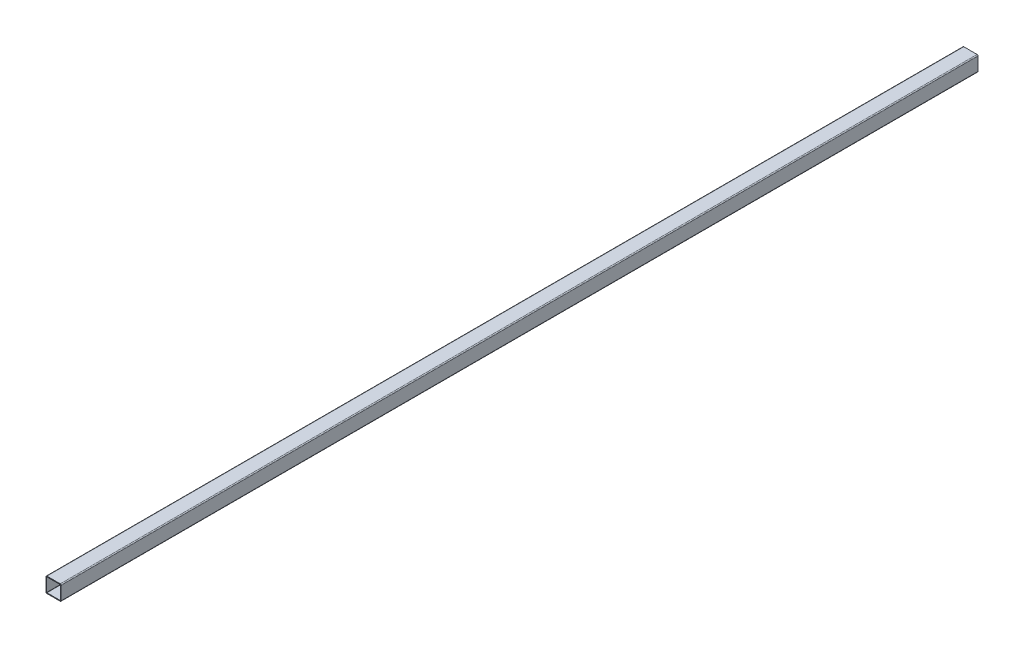
from build123d import *

# Parameters (mm, degrees)
BOSS_EXTRUDE1_DEPTH      = 968
BOSS_EXTRUDE1_DEPTH_BACK = 968


with BuildPart() as part:
    # Sketch1 → Boss-Extrude1 (new, two sides: drawn at the far end of the back side and taken through both)
    with BuildSketch(Plane.XY.offset(-BOSS_EXTRUDE1_DEPTH_BACK)):
        with BuildLine():
            Line((-14, -16), (14, -16))
            ThreePointArc((14, -16), (15.414213562, -15.414213562), (16, -14))
            Line((16, -14), (16, 14))
            ThreePointArc((16, 14), (15.414213562, 15.414213562), (14, 16))
            Line((14, 16), (-14, 16))
            ThreePointArc((-14, 16), (-15.414213562, 15.414213562), (-16, 14))
            Line((-16, 14), (-16, -14))
            ThreePointArc((-16, -14), (-15.414213562, -15.414213562), (-14, -16))
        make_face()
        with BuildLine():
            Line((-14, 14.48), (14, 14.48))
            ThreePointArc((14, 14.48), (14.339411255, 14.339411255), (14.48, 14))
            Line((14.48, 14), (14.48, -14))
            ThreePointArc((14.48, -14), (14.339411255, -14.339411255), (14, -14.48))
            Line((14, -14.48), (-14, -14.48))
            ThreePointArc((-14, -14.48), (-14.339411255, -14.339411255), (-14.48, -14))
            Line((-14.48, -14), (-14.48, 14))
            ThreePointArc((-14.48, 14), (-14.339411255, 14.339411255), (-14, 14.48))
        make_face(mode=Mode.SUBTRACT)
    extrude(amount=BOSS_EXTRUDE1_DEPTH + BOSS_EXTRUDE1_DEPTH_BACK)


solid = part.part
